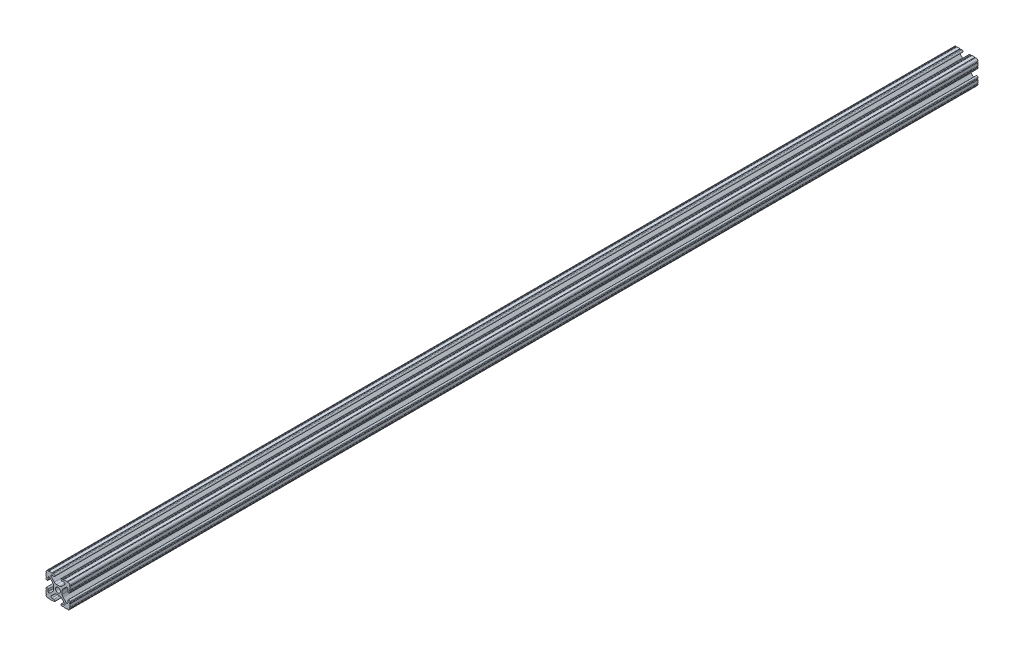
from build123d import *

# Parameters (mm, degrees)
SKETCH1_R           = 2.6035
BOSS_EXTRUDE1_DEPTH = 965.2


with BuildPart() as part:
    # Sketch1 → Boss-Extrude1 (new body)
    with BuildSketch(Plane(origin=(0, 0, -450.85), x_dir=(-1, 0, 0), z_dir=(0, 0, -1))):
        with BuildLine():
            Line((12.7, -9.5504), (12.7, -6.3330836))
            ThreePointArc((12.7, -6.3330836), (12.192, -5.8250836), (12.7, -5.3170836))
            Line((12.7, -5.3170836), (12.7, -4.3434))
            ThreePointArc((12.7, -4.3434), (11.5951, -3.2385), (10.4902, -4.3434))
            Line((10.4902, -4.3434), (10.4902, -6.474794456))
            ThreePointArc((10.4902, -6.474794456), (9.863006367, -7.413456061), (8.75577951, -7.193214945))
            Line((8.75577951, -7.193214945), (5.42573597, -3.863171405))
            ThreePointArc((5.42573597, -3.863171405), (4.737482484, -2.833127272), (4.4958, -1.618107374))
            Line((4.4958, -1.618107374), (4.4958, 1.618107374))
            ThreePointArc((4.4958, 1.618107374), (4.737482484, 2.833127272), (5.42573597, 3.863171405))
            Line((5.42573597, 3.863171405), (8.75577951, 7.193214945))
            ThreePointArc((8.75577951, 7.193214945), (9.863006367, 7.413456061), (10.4902, 6.474794456))
            Line((10.4902, 6.474794456), (10.4902, 4.343399971))
            ThreePointArc((10.4902, 4.343399971), (11.5951, 3.238499971), (12.7, 4.343399971))
            Line((12.7, 4.343399971), (12.7, 5.3170836))
            ThreePointArc((12.7, 5.3170836), (12.192, 5.8250836), (12.7, 6.3330836))
            Line((12.7, 6.3330836), (12.7, 9.5504))
            ThreePointArc((12.7, 9.5504), (12.192000006, 10.058323491), (12.699846982, 10.566399977))
            ThreePointArc((12.699846982, 10.566399977), (12.082522516, 12.082522516), (10.566399977, 12.699846982))
            ThreePointArc((10.566399977, 12.699846982), (10.058323491, 12.192000006), (9.5504, 12.7))
            Line((9.5504, 12.7), (6.3330836, 12.7))
            ThreePointArc((6.3330836, 12.7), (5.8250836, 12.192), (5.3170836, 12.7))
            Line((5.3170836, 12.7), (4.3434, 12.7))
            ThreePointArc((4.3434, 12.7), (3.2385, 11.5951), (4.3434, 10.4902))
            Line((4.3434, 10.4902), (6.474794456, 10.4902))
            ThreePointArc((6.474794456, 10.4902), (7.413456061, 9.863006367), (7.193214945, 8.75577951))
            Line((7.193214945, 8.75577951), (3.863171405, 5.42573597))
            ThreePointArc((3.863171405, 5.42573597), (2.833127272, 4.737482484), (1.618107374, 4.4958))
            Line((1.618107374, 4.4958), (-1.618107374, 4.4958))
            ThreePointArc((-1.618107374, 4.4958), (-2.833127272, 4.737482484), (-3.863171405, 5.42573597))
            Line((-3.863171405, 5.42573597), (-7.193214945, 8.75577951))
            ThreePointArc((-7.193214945, 8.75577951), (-7.413456061, 9.863006367), (-6.474794456, 10.4902))
            Line((-6.474794456, 10.4902), (-4.343399971, 10.4902))
            ThreePointArc((-4.343399971, 10.4902), (-3.238499971, 11.5951), (-4.343399971, 12.7))
            Line((-4.343399971, 12.7), (-5.3170836, 12.7))
            ThreePointArc((-5.3170836, 12.7), (-5.8250836, 12.192), (-6.3330836, 12.7))
            Line((-6.3330836, 12.7), (-9.5504, 12.7))
            ThreePointArc((-9.5504, 12.7), (-10.058323491, 12.192000006), (-10.566399977, 12.699846982))
            ThreePointArc((-10.566399977, 12.699846982), (-12.082522516, 12.082522516), (-12.699846982, 10.566399977))
            ThreePointArc((-12.699846982, 10.566399977), (-12.192000006, 10.058323491), (-12.7, 9.5504))
            Line((-12.7, 9.5504), (-12.7, 6.3330836))
            ThreePointArc((-12.7, 6.3330836), (-12.192, 5.8250836), (-12.7, 5.3170836))
            Line((-12.7, 5.3170836), (-12.7, 4.3434))
            ThreePointArc((-12.7, 4.3434), (-11.5951, 3.2385), (-10.4902, 4.3434))
            Line((-10.4902, 4.3434), (-10.4902, 6.474794456))
            ThreePointArc((-10.4902, 6.474794456), (-9.863006367, 7.413456061), (-8.75577951, 7.193214945))
            Line((-8.75577951, 7.193214945), (-5.42573597, 3.863171405))
            ThreePointArc((-5.42573597, 3.863171405), (-4.737482484, 2.833127272), (-4.4958, 1.618107374))
            Line((-4.4958, 1.618107374), (-4.4958, -1.618107374))
            ThreePointArc((-4.4958, -1.618107374), (-4.737482484, -2.833127272), (-5.42573597, -3.863171405))
            Line((-5.42573597, -3.863171405), (-8.75577951, -7.193214945))
            ThreePointArc((-8.75577951, -7.193214945), (-9.863006367, -7.413456061), (-10.4902, -6.474794456))
            Line((-10.4902, -6.474794456), (-10.4902, -4.343399971))
            ThreePointArc((-10.4902, -4.343399971), (-11.5951, -3.238499971), (-12.7, -4.343399971))
            Line((-12.7, -4.343399971), (-12.7, -5.3170836))
            ThreePointArc((-12.7, -5.3170836), (-12.192, -5.8250836), (-12.7, -6.3330836))
            Line((-12.7, -6.3330836), (-12.7, -9.5504))
            ThreePointArc((-12.7, -9.5504), (-12.192000006, -10.058323491), (-12.699846982, -10.566399977))
            ThreePointArc((-12.699846982, -10.566399977), (-12.082522516, -12.082522516), (-10.566399977, -12.699846982))
            ThreePointArc((-10.566399977, -12.699846982), (-10.058323491, -12.192000006), (-9.5504, -12.7))
            Line((-9.5504, -12.7), (-6.3330836, -12.7))
            ThreePointArc((-6.3330836, -12.7), (-5.8250836, -12.192), (-5.3170836, -12.7))
            Line((-5.3170836, -12.7), (-4.3434, -12.7))
            ThreePointArc((-4.3434, -12.7), (-3.2385, -11.5951), (-4.3434, -10.4902))
            Line((-4.3434, -10.4902), (-6.474794456, -10.4902))
            ThreePointArc((-6.474794456, -10.4902), (-7.413456061, -9.863006367), (-7.193214945, -8.75577951))
            Line((-7.193214945, -8.75577951), (-3.863171405, -5.42573597))
            ThreePointArc((-3.863171405, -5.42573597), (-2.833127272, -4.737482484), (-1.618107374, -4.4958))
            Line((-1.618107374, -4.4958), (1.618107374, -4.4958))
            ThreePointArc((1.618107374, -4.4958), (2.833127272, -4.737482484), (3.863171405, -5.42573597))
            Line((3.863171405, -5.42573597), (7.193214945, -8.75577951))
            ThreePointArc((7.193214945, -8.75577951), (7.413456061, -9.863006367), (6.474794456, -10.4902))
            Line((6.474794456, -10.4902), (4.343399971, -10.4902))
            ThreePointArc((4.343399971, -10.4902), (3.238499971, -11.5951), (4.343399971, -12.7))
            Line((4.343399971, -12.7), (5.3170836, -12.7))
            ThreePointArc((5.3170836, -12.7), (5.8250836, -12.192), (6.3330836, -12.7))
            Line((6.3330836, -12.7), (9.5504, -12.7))
            ThreePointArc((9.5504, -12.7), (10.058323491, -12.192000006), (10.566399977, -12.699846982))
            ThreePointArc((10.566399977, -12.699846982), (12.082522516, -12.082522516), (12.699846982, -10.566399977))
            ThreePointArc((12.699846982, -10.566399977), (12.192000006, -10.058323491), (12.7, -9.5504))
        make_face()
        Circle(SKETCH1_R, mode=Mode.SUBTRACT)
    extrude(amount=-BOSS_EXTRUDE1_DEPTH)


solid = part.part
